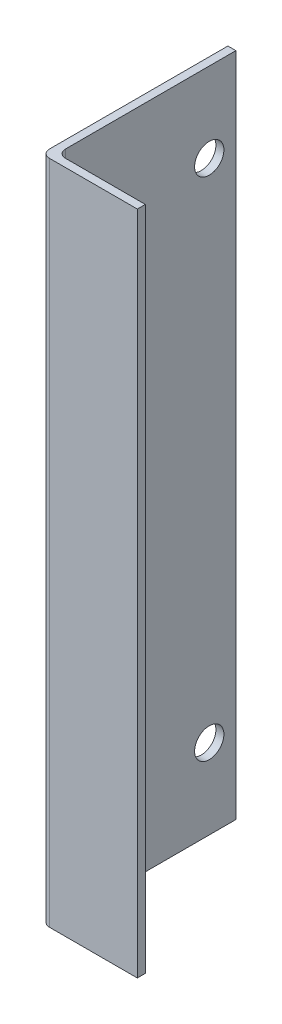
from build123d import *

# Parameters (mm, degrees)
BOSS_EXTRUDE1_DEPTH = 125
FILLET1_R           = 1.5
FILLET2_R           = 1.5
SKETCH2_R           = 2.75
CUT_EXTRUDE1_DEPTH  = 2.5


with BuildPart() as part:
    # Sketch1 → Boss-Extrude1 (new body)
    with BuildSketch(Plane(origin=(0, 0, 0), x_dir=(1, 0, 0), z_dir=(0, 1, 0))):
        Polygon((0, 0), (0, 35), (1.5, 35), (1.5, 1.5), (18, 1.5), (18, 0), align=None)
    extrude(amount=BOSS_EXTRUDE1_DEPTH)

    # Fillet1
    fillet1_edges = [part.edges().sort_by_distance(p)[0] for p in [
        (1.5, 62.5, -1.5),
    ]]
    fillet(fillet1_edges, radius=FILLET1_R)

    # Fillet2
    fillet2_edges = [part.edges().sort_by_distance(p)[0] for p in [
        (0, 62.5, 0),
    ]]
    fillet(fillet2_edges, radius=FILLET2_R)

    # Sketch2 → Cut-Extrude1 (cut, through all)
    with BuildSketch(Plane(origin=(1.5, 0, 0), x_dir=(0, 0, -1), z_dir=(1, 0, 0))):
        with Locations((30, 110)):
            Circle(SKETCH2_R)
        with Locations((30, 15)):
            Circle(SKETCH2_R)
    extrude(amount=-CUT_EXTRUDE1_DEPTH, mode=Mode.SUBTRACT)


solid = part.part
